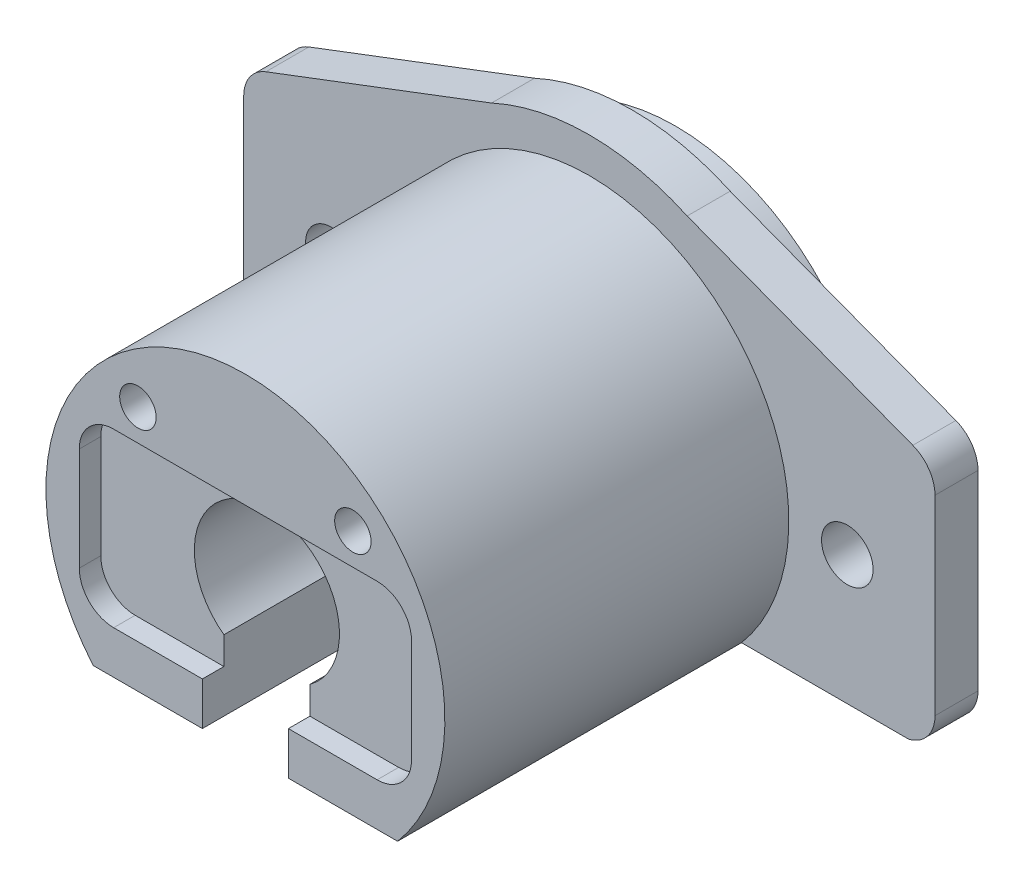
from build123d import *

# Parameters (mm, degrees)
BOSS_EXTRUDE1_DEPTH      = 3.175
FILLET2_R                = 2.54
SKETCH2_R                = 1.905
CUT_EXTRUDE1_DEPTH       = 3.175
SKETCH3_R                = 14.732
BOSS_EXTRUDE2_DEPTH      = 25.4
BOSS_EXTRUDE2_DEPTH_BACK = 6.35
SKETCH4_R                = 5.3594
CUT_EXTRUDE2_DEPTH       = 32.75
SKETCH5_W                = 6.35
SKETCH5_H                = 39.068308628
CUT_EXTRUDE3_DEPTH       = 18.3355
SKETCH6_W                = 53.776347276
SKETCH6_H                = 42.154212624
CUT_EXTRUDE4_DEPTH       = 3.175
CUT_EXTRUDE4_DEPTH_BACK  = 5.342269076
SKETCH8_W                = 24.5364
SKETCH8_H                = 12.7
CUT_EXTRUDE5_DEPTH       = 1.5875
FILLET4_R                = 2.54
SKETCH9_R                = 1.3462
CUT_EXTRUDE6_DEPTH       = 1.5875
CUT_EXTRUDE6_DEPTH_BACK  = 9.525
SKETCH10_W               = 22.477206144
SKETCH10_H               = 0.381
CUT_EXTRUDE7_DEPTH       = 0.79375


with BuildPart() as part:
    # Sketch1 → Boss-Extrude1 (new body)
    with BuildSketch(Plane.XY):
        with BuildLine():
            Line((7.225764579, -15.757788122), (25.527, -8.80240377))
            Line((25.527, -8.80240377), (25.527, 8.80240377))
            Line((25.527, 8.80240377), (7.225764579, 15.757788122))
            ThreePointArc((7.225764579, 15.757788122), (0, 17.3355), (-7.225764579, 15.757788122))
            Line((-7.225764579, 15.757788122), (-25.527, 8.80240377))
            Line((-25.527, 8.80240377), (-25.527, -8.80240377))
            Line((-25.527, -8.80240377), (-7.225764579, -15.757788122))
            ThreePointArc((-7.225764579, -15.757788122), (0, -17.3355), (7.225764579, -15.757788122))
        make_face()
    extrude(amount=BOSS_EXTRUDE1_DEPTH)

    # Fillet2
    fillet2_edges = [part.edges().sort_by_distance(p)[0] for p in [
        (-25.527, -8.80240377, 1.5875),
        (-25.527, 8.80240377, 1.5875),
        (25.527, 8.80240377, 1.5875),
        (25.527, -8.80240377, 1.5875),
    ]]
    fillet(fillet2_edges, radius=FILLET2_R)

    # Sketch2 → Cut-Extrude1 (cut)
    with BuildSketch(Plane.XY.offset(3.175)):
        with Locations((19.05, 0)):
            Circle(SKETCH2_R)
        with Locations((-19.05, 0)):
            Circle(SKETCH2_R)
    extrude(amount=-CUT_EXTRUDE1_DEPTH, mode=Mode.SUBTRACT)

    # Sketch3 → Boss-Extrude2 (add, two sides)
    with BuildSketch(Plane.XY.offset(3.175)) as boss_extrude2_sk:
        Circle(SKETCH3_R)
    extrude(amount=BOSS_EXTRUDE2_DEPTH)
    extrude(boss_extrude2_sk.sketch, amount=-BOSS_EXTRUDE2_DEPTH_BACK)

    # Sketch4 → Cut-Extrude2 (cut, through all)
    with BuildSketch(Plane.XY.offset(28.575)):
        Circle(SKETCH4_R)
    extrude(amount=-CUT_EXTRUDE2_DEPTH, mode=Mode.SUBTRACT)

    # Sketch5 → Cut-Extrude3 (cut, through all)
    with BuildSketch(Plane(origin=(0, 0, 0), x_dir=(1, 0, 0), z_dir=(0, 1, 0))):
        with Locations((0, -13.377136562)):
            Rectangle(SKETCH5_W, SKETCH5_H)
    extrude(amount=-CUT_EXTRUDE3_DEPTH, mode=Mode.SUBTRACT)

    # Sketch6 → Cut-Extrude4 (cut, two sides)
    with BuildSketch(Plane(origin=(0, -12.7, 0), x_dir=(1, 0, 0), z_dir=(0, 1, 0))) as cut_extrude4_sk:
        with Locations((0, -11.260406522)):
            Rectangle(SKETCH6_W, SKETCH6_H)
    extrude(amount=CUT_EXTRUDE4_DEPTH, mode=Mode.SUBTRACT)
    extrude(cut_extrude4_sk.sketch, amount=-CUT_EXTRUDE4_DEPTH_BACK, mode=Mode.SUBTRACT)

    # Sketch8 → Cut-Extrude5 (cut)
    with BuildSketch(Plane.XY.offset(28.575)):
        Rectangle(SKETCH8_W, SKETCH8_H)
    extrude(amount=-CUT_EXTRUDE5_DEPTH, mode=Mode.SUBTRACT)

    # Fillet4
    fillet4_edges = [part.edges().sort_by_distance(p)[0] for p in [
        (12.2682, -6.35, 27.78125),
        (12.2682, 6.35, 27.78125),
        (-12.2682, -6.35, 27.78125),
        (-12.2682, 6.35, 27.78125),
    ]]
    fillet(fillet4_edges, radius=FILLET4_R)

    # Sketch9 → Cut-Extrude6 (cut, two sides)
    with BuildSketch(Plane.XY.offset(26.9875)) as cut_extrude6_sk:
        with Locations((7.9375, 8.662302327)):
            Circle(SKETCH9_R)
        with Locations((-7.9375, 8.662302327)):
            Circle(SKETCH9_R)
    extrude(amount=CUT_EXTRUDE6_DEPTH, mode=Mode.SUBTRACT)
    extrude(cut_extrude6_sk.sketch, amount=-CUT_EXTRUDE6_DEPTH_BACK, mode=Mode.SUBTRACT)

    # Sketch10 → Cut-Extrude7 (cut)
    with BuildSketch(Plane.XZ.offset(9.525)):
        with Locations((0, 11.7475)):
            Rectangle(SKETCH10_W, SKETCH10_H)
        with Locations((0, 3.2475)):
            Rectangle(SKETCH10_W, SKETCH10_H)
        with BuildLine():
            Line((-5.28614634, 12.786699481), (-5.143678391, 12.786699481))
            add(Edge.make_bspline(
                [(-5.143678391, 12.786699481), (-5.14753808, 12.770719033), (-5.155083456, 12.739478564), (-5.170821284, 12.694843842), (-5.187965946, 12.652605673), (-5.208553147, 12.613554954), (-5.231008904, 12.576906881), (-5.25673671, 12.54349267), (-5.284549584, 12.512462504), (-5.315313043, 12.484924714), (-5.347574972, 12.459988387), (-5.38178996, 12.4387272), (-5.417269629, 12.420437317), (-5.454259801, 12.405369569), (-5.4928706, 12.394018706), (-5.532752965, 12.385783298), (-5.574011409, 12.380435185), (-5.602018352, 12.379913232), (-5.616239489, 12.379648199)],
                knots=[0, 0, 0, 0, 4.9287e-05, 9.6353e-05, 0.000141828, 0.000185921, 0.00022863, 0.000270609, 0.000312258, 0.000353458, 0.000394292, 0.00043444, 0.000474121, 0.000513923, 0.000554069, 0.000594671, 0.000636008, 0.000678651, 0.000678651, 0.000678651, 0.000678651], degree=3))
            add(Edge.make_bspline(
                [(-5.616239489, 12.379648199), (-5.636959875, 12.380273778), (-5.677948677, 12.381511291), (-5.738166201, 12.392811768), (-5.796235509, 12.410693882), (-5.851520989, 12.435401608), (-5.902873635, 12.465875853), (-5.948564691, 12.502145573), (-5.987974837, 12.543510971), (-6.021037644, 12.589200384), (-6.046925233, 12.638029847), (-6.06601441, 12.688285633), (-6.077635672, 12.739848527), (-6.079141782, 12.774663436), (-6.07989634, 12.792105631)],
                knots=[0, 0, 0, 0, 6.211e-05, 0.000122866, 0.000183117, 0.000244047, 0.000304093, 0.000361803, 0.000418486, 0.000474973, 0.000530457, 0.000583793, 0.000635878, 0.00068817, 0.00068817, 0.00068817, 0.00068817], degree=3))
            add(Edge.make_bspline(
                [(-6.07989634, 12.792105631), (-6.079368568, 12.808890855), (-6.078335801, 12.841736936), (-6.069566584, 12.889689186), (-6.054809065, 12.934883769), (-6.034366708, 12.977510939), (-6.007904648, 13.01730042), (-5.975849532, 13.054341735), (-5.93797511, 13.088799174), (-5.909273592, 13.108538364), (-5.894497201, 13.118700683)],
                knots=[0, 0, 0, 0, 5.0327e-05, 9.8482e-05, 0.000145647, 0.000192584, 0.00023986, 0.000288564, 0.000339219, 0.000392971, 0.000392971, 0.000392971, 0.000392971], degree=3))
            add(Edge.make_bspline(
                [(-5.894497201, 13.118700683), (-5.911405986, 13.126825507), (-5.944961473, 13.142949221), (-5.990237619, 13.175072719), (-6.031965503, 13.211251751), (-6.054962837, 13.239800604), (-6.066539969, 13.254172438)],
                knots=[0, 0, 0, 0, 5.6181e-05, 0.00011149, 0.000165999, 0.000221257, 0.000221257, 0.000221257, 0.000221257], degree=3))
            add(Edge.make_bspline(
                [(-6.066539969, 13.254172438), (-6.07418183, 13.26462966), (-6.089340412, 13.285372862), (-6.107998245, 13.318743166), (-6.125118065, 13.352372871), (-6.137717756, 13.387584253), (-6.148590791, 13.42324626), (-6.155744885, 13.460122559), (-6.160337528, 13.497862792), (-6.160982429, 13.523406441), (-6.161306596, 13.536246256)],
                knots=[0, 0, 0, 0, 3.8818e-05, 7.7e-05, 0.000114547, 0.000151879, 0.000189009, 0.000226305, 0.000264409, 0.000302921, 0.000302921, 0.000302921, 0.000302921], degree=3))
            add(Edge.make_bspline(
                [(-6.161306596, 13.536246256), (-6.160490747, 13.558474667), (-6.158862887, 13.602826883), (-6.144375392, 13.668371456), (-6.121776732, 13.732323241), (-6.090281753, 13.793775277), (-6.051138262, 13.851096391), (-6.004826188, 13.902530832), (-5.951296217, 13.94633914), (-5.892106911, 13.983266816), (-5.827733123, 14.012531583), (-5.759153873, 14.033619219), (-5.686775199, 14.046268843), (-5.637278697, 14.047786562), (-5.612105374, 14.048558455)],
                knots=[0, 0, 0, 0, 6.6613e-05, 0.000132912, 0.000200403, 0.000269665, 0.000339437, 0.000408104, 0.00047655, 0.00054626, 0.000616846, 0.000688063, 0.000760995, 0.000836477, 0.000836477, 0.000836477, 0.000836477], degree=3))
            add(Edge.make_bspline(
                [(-5.612105374, 14.048558455), (-5.595134117, 14.048161224), (-5.561740342, 14.047379605), (-5.512628969, 14.042131441), (-5.465849206, 14.032285503), (-5.420946805, 14.019902874), (-5.37859945, 14.002782501), (-5.338198015, 13.982371845), (-5.299919594, 13.958147501), (-5.263991509, 13.930068731), (-5.230452146, 13.898638747), (-5.200155975, 13.863335408), (-5.172767802, 13.824817599), (-5.148461649, 13.782738843), (-5.127135219, 13.737216999), (-5.10924746, 13.688069652), (-5.093629236, 13.635677814), (-5.08635362, 13.599177038), (-5.082620698, 13.580449481)],
                knots=[0, 0, 0, 0, 5.0917e-05, 0.000100188, 0.000147899, 0.000194202, 0.000239731, 0.000284673, 0.000329844, 0.00037539, 0.000421283, 0.000467504, 0.000514711, 0.000562874, 0.000613093, 0.000665313, 0.000719655, 0.000776914, 0.000776914, 0.000776914, 0.000776914], degree=3))
            Line((-5.082620698, 13.580449481), (-5.225088647, 13.580449481))
            add(Edge.make_bspline(
                [(-5.225088647, 13.580449481), (-5.228800354, 13.592672783), (-5.236019947, 13.616448168), (-5.248309147, 13.650665736), (-5.262310113, 13.682033853), (-5.277329931, 13.710782626), (-5.29310444, 13.73719518), (-5.310755138, 13.760573099), (-5.328974715, 13.781943208), (-5.342708564, 13.793983086), (-5.349430094, 13.799875563)],
                knots=[0, 0, 0, 0, 3.8321e-05, 7.4538e-05, 0.00010899, 0.000141279, 0.000171821, 0.000201141, 0.000229083, 0.000255865, 0.000255865, 0.000255865, 0.000255865], degree=3))
            add(Edge.make_bspline(
                [(-5.349430094, 13.799875563), (-5.358319534, 13.806725446), (-5.376070974, 13.820404067), (-5.404979522, 13.837909714), (-5.435488831, 13.852894129), (-5.467853327, 13.86507409), (-5.502077352, 13.874216807), (-5.538022079, 13.880797305), (-5.575746483, 13.885141456), (-5.601492652, 13.885536214), (-5.614649444, 13.885737942)],
                knots=[0, 0, 0, 0, 3.3646e-05, 6.7188e-05, 0.000101179, 0.000135496, 0.000170751, 0.000207301, 0.000245053, 0.000284507, 0.000284507, 0.000284507, 0.000284507], degree=3))
            add(Edge.make_bspline(
                [(-5.614649444, 13.885737942), (-5.629505699, 13.88545904), (-5.658555821, 13.88491367), (-5.700941465, 13.879883698), (-5.741277382, 13.872590083), (-5.779151943, 13.86118145), (-5.815080528, 13.84749491), (-5.848261107, 13.829576718), (-5.879669148, 13.809341017), (-5.908384541, 13.785803005), (-5.934272872, 13.760360961), (-5.956643251, 13.73336922), (-5.976018557, 13.705664701), (-5.99159307, 13.676601114), (-6.00391324, 13.64646355), (-6.012295235, 13.615139202), (-6.018124703, 13.582891843), (-6.018599364, 13.560971159), (-6.018838647, 13.549920635)],
                knots=[0, 0, 0, 0, 4.455e-05, 8.7113e-05, 0.000127902, 0.000167348, 0.000205615, 0.000243028, 0.00028025, 0.00031755, 0.000354203, 0.000388976, 0.000422584, 0.000455451, 0.000487694, 0.00052002, 0.000552591, 0.000585702, 0.000585702, 0.000585702, 0.000585702], degree=3))
            add(Edge.make_bspline(
                [(-6.018838647, 13.549920635), (-6.018143098, 13.535129993), (-6.01675546, 13.505622304), (-6.006205047, 13.462193628), (-5.988695923, 13.420334092), (-5.964660502, 13.380591885), (-5.934700766, 13.344189456), (-5.900232913, 13.311605358), (-5.860521504, 13.284474083), (-5.823764224, 13.26578099), (-5.791121185, 13.25332652), (-5.763242373, 13.244593058), (-5.732003298, 13.237611855), (-5.697779319, 13.230858869), (-5.660425993, 13.22519761), (-5.619909698, 13.22045608), (-5.576214124, 13.216668071), (-5.545964978, 13.214975524), (-5.530377109, 13.214103327)],
                knots=[0, 0, 0, 0, 4.4341e-05, 8.8462e-05, 0.000133228, 0.000180022, 0.000227256, 0.000274279, 0.000321825, 0.000371033, 0.00039761, 0.000426578, 0.00045859, 0.000493578, 0.000531223, 0.000571891, 0.000615941, 0.000662776, 0.000662776, 0.000662776, 0.000662776], degree=3))
            Line((-5.530377109, 13.214103327), (-5.530377109, 13.051282814))
            add(Edge.make_bspline(
                [(-5.530377109, 13.051282814), (-5.550009642, 13.050900044), (-5.588451503, 13.050150555), (-5.644763086, 13.042952335), (-5.698445621, 13.031268607), (-5.748691645, 13.014956605), (-5.794252212, 12.995098032), (-5.834156802, 12.972864017), (-5.866969841, 12.94721355), (-5.893279013, 12.919359165), (-5.912792811, 12.889294988), (-5.927196744, 12.858102647), (-5.935716367, 12.825201858), (-5.936855707, 12.802753287), (-5.937428391, 12.791469613)],
                knots=[0, 0, 0, 0, 5.8874e-05, 0.000115279, 0.000169985, 0.000223486, 0.00027347, 0.00031891, 0.000360133, 0.000397935, 0.000433304, 0.000467176, 0.00050065, 0.00053448, 0.00053448, 0.00053448, 0.00053448], degree=3))
            add(Edge.make_bspline(
                [(-5.937428391, 12.791469613), (-5.937244561, 12.783177951), (-5.936878841, 12.766682082), (-5.932082435, 12.742506726), (-5.92520795, 12.719070088), (-5.915220717, 12.696646008), (-5.902304188, 12.675163203), (-5.886677111, 12.65454321), (-5.8682999, 12.634589127), (-5.847291894, 12.615741039), (-5.823846422, 12.598777427), (-5.798904492, 12.583654603), (-5.772368867, 12.570938461), (-5.744412471, 12.560397643), (-5.714884188, 12.552482367), (-5.683939358, 12.546795415), (-5.651514368, 12.543240772), (-5.629392934, 12.542728914), (-5.618147541, 12.542468712)],
                knots=[0, 0, 0, 0, 2.4837e-05, 4.9413e-05, 7.3659e-05, 9.8004e-05, 0.000122819, 0.000148705, 0.000175488, 0.000204089, 0.000233221, 0.000262181, 0.000291481, 0.000321369, 0.000351687, 0.00038306, 0.000415685, 0.000449418, 0.000449418, 0.000449418, 0.000449418], degree=3))
            add(Edge.make_bspline(
                [(-5.618147541, 12.542468712), (-5.600071366, 12.54309857), (-5.564764392, 12.544328829), (-5.513875234, 12.555142251), (-5.466615709, 12.572275004), (-5.430613484, 12.592962752), (-5.403983061, 12.613313954), (-5.38458836, 12.630822093), (-5.365889881, 12.650672737), (-5.34862137, 12.673410367), (-5.331748061, 12.698253126), (-5.315431069, 12.725337841), (-5.300194496, 12.755050658), (-5.290919745, 12.775945568), (-5.28614634, 12.786699481)],
                knots=[0, 0, 0, 0, 5.4175e-05, 0.000105816, 0.000155319, 0.000204466, 0.000229653, 0.000255773, 0.000282772, 0.000311332, 0.000341321, 0.000372844, 0.000406126, 0.000441419, 0.000441419, 0.000441419, 0.000441419], degree=3))
        make_face()
        with BuildLine():
            Line((-6.405537365, 12.847757173), (-6.548005314, 12.847757173))
            Line((-6.548005314, 12.847757173), (-6.548005314, 13.049374761))
            add(Edge.make_bspline(
                [(-6.548005314, 13.049374761), (-6.560861932, 13.031762553), (-6.585454706, 12.998073051), (-6.625395295, 12.953183822), (-6.665982481, 12.915714758), (-6.69500592, 12.895787842), (-6.708917774, 12.88623624)],
                knots=[0, 0, 0, 0, 6.5383e-05, 0.000125068, 0.000180002, 0.000230574, 0.000230574, 0.000230574, 0.000230574], degree=3))
            add(Edge.make_bspline(
                [(-6.708917774, 12.88623624), (-6.727906388, 12.877162378), (-6.765551864, 12.859173184), (-6.82515987, 12.840924392), (-6.886153738, 12.829709792), (-6.927341749, 12.828176098), (-6.948060402, 12.827404609)],
                knots=[0, 0, 0, 0, 6.306e-05, 0.000125019, 0.000186401, 0.00024853, 0.00024853, 0.00024853, 0.00024853], degree=3))
            add(Edge.make_bspline(
                [(-6.948060402, 12.827404609), (-6.962072065, 12.827879989), (-6.989800392, 12.828820739), (-7.030894305, 12.834907351), (-7.070811833, 12.84555568), (-7.109296504, 12.860009459), (-7.145328256, 12.878080347), (-7.178448416, 12.898833967), (-7.208076813, 12.922321066), (-7.234655208, 12.949065303), (-7.258342434, 12.980576772), (-7.279979324, 13.017452829), (-7.300237317, 13.060227018), (-7.311394584, 13.091241791), (-7.317268635, 13.107570374)],
                knots=[0, 0, 0, 0, 4.2036e-05, 8.3187e-05, 0.0001243, 0.000165764, 0.000206296, 0.000245028, 0.000282822, 0.000319476, 0.000357829, 0.000400751, 0.000447551, 0.000499585, 0.000499585, 0.000499585, 0.000499585], degree=3))
            add(Edge.make_bspline(
                [(-7.317268635, 13.107570374), (-7.323487781, 13.096356206), (-7.335726186, 13.074288299), (-7.356273903, 13.043054412), (-7.377809877, 13.013847709), (-7.400482804, 12.986607643), (-7.424387961, 12.96155121), (-7.44913998, 12.938166651), (-7.475293915, 12.917103745), (-7.511466936, 12.892450329), (-7.558414221, 12.866281719), (-7.617855181, 12.843874466), (-7.679575841, 12.829900982), (-7.721597166, 12.828240858), (-7.742764428, 12.827404609)],
                knots=[0, 0, 0, 0, 3.8458e-05, 7.568e-05, 0.000112061, 0.000147281, 0.000181922, 0.000215896, 0.00024937, 0.000282536, 0.000347153, 0.000410056, 0.000472557, 0.000535997, 0.000535997, 0.000535997, 0.000535997], degree=3))
            add(Edge.make_bspline(
                [(-7.742764428, 12.827404609), (-7.762217615, 12.828128945), (-7.800289389, 12.829546541), (-7.855621696, 12.840941462), (-7.907445638, 12.859801097), (-7.955211935, 12.886323619), (-7.998365539, 12.919494445), (-8.036018784, 12.95900803), (-8.067343788, 13.004720057), (-8.088285409, 13.047379627), (-8.102226551, 13.085112424), (-8.110933359, 13.117408605), (-8.118476625, 13.152983313), (-8.124872176, 13.191807935), (-8.129495867, 13.23396108), (-8.132933065, 13.279462115), (-8.135256221, 13.328350579), (-8.135420586, 13.362080614), (-8.135505314, 13.37946791)],
                knots=[0, 0, 0, 0, 5.8321e-05, 0.000114139, 0.000168668, 0.000223185, 0.000277378, 0.000331363, 0.00038623, 0.000442976, 0.00047346, 0.00050679, 0.000543216, 0.000582531, 0.000624778, 0.000670388, 0.000719412, 0.000771569, 0.000771569, 0.000771569, 0.000771569], degree=3))
            Line((-8.135505314, 13.37946791), (-8.135505314, 14.007853327))
            Line((-8.135505314, 14.007853327), (-7.993037365, 14.007853327))
            Line((-7.993037365, 14.007853327), (-7.993037365, 13.378831893))
            add(Edge.make_bspline(
                [(-7.993037365, 13.378831893), (-7.993002211, 13.363990753), (-7.99293465, 13.335468341), (-7.991710641, 13.294532695), (-7.98941607, 13.25721717), (-7.986691869, 13.223473057), (-7.98300953, 13.193310954), (-7.978147703, 13.166815301), (-7.973037952, 13.143865283), (-7.964528973, 13.118433236), (-7.951051695, 13.09040313), (-7.930152088, 13.060388864), (-7.904204064, 13.034078806), (-7.874044919, 13.01110059), (-7.839649565, 12.992781068), (-7.801893206, 12.979206724), (-7.760911584, 12.971181366), (-7.732518003, 12.97031617), (-7.717959741, 12.969872558)],
                knots=[0, 0, 0, 0, 4.4522e-05, 8.5565e-05, 0.000122839, 0.000156669, 0.00018712, 0.000213942, 0.000237468, 0.000257581, 0.000294278, 0.00033036, 0.000366791, 0.000404698, 0.000443683, 0.000483214, 0.000524689, 0.00056833, 0.00056833, 0.00056833, 0.00056833], degree=3))
            add(Edge.make_bspline(
                [(-7.717959741, 12.969872558), (-7.699984943, 12.97070787), (-7.664388234, 12.972362095), (-7.612207818, 12.984386988), (-7.562730863, 13.004877465), (-7.516141008, 13.032497188), (-7.473624855, 13.066569764), (-7.436907429, 13.106868298), (-7.406600556, 13.152523769), (-7.386073533, 13.19476936), (-7.373105346, 13.23271974), (-7.364547476, 13.265875084), (-7.357850479, 13.303659347), (-7.351691263, 13.345629467), (-7.347534524, 13.392142826), (-7.343862501, 13.442912214), (-7.342121931, 13.498285179), (-7.341880609, 13.536669547), (-7.341755314, 13.55659882)],
                knots=[0, 0, 0, 0, 5.3902e-05, 0.000106746, 0.000159659, 0.00021398, 0.000268711, 0.000322511, 0.000376842, 0.000432598, 0.000462869, 0.000497038, 0.00053521, 0.000577934, 0.00062426, 0.000675262, 0.000730628, 0.000790417, 0.000790417, 0.000790417, 0.000790417], degree=3))
            Line((-7.341755314, 13.55659882), (-7.341755314, 14.007853327))
            Line((-7.341755314, 14.007853327), (-7.199287365, 14.007853327))
            Line((-7.199287365, 14.007853327), (-7.199287365, 13.417946977))
            add(Edge.make_bspline(
                [(-7.199287365, 13.417946977), (-7.199252952, 13.401303748), (-7.199186744, 13.369283847), (-7.197951588, 13.323369624), (-7.195714268, 13.28159613), (-7.192824595, 13.244068241), (-7.189688287, 13.210684016), (-7.184725085, 13.181552841), (-7.179551195, 13.156553879), (-7.171656346, 13.128869676), (-7.157976008, 13.098845387), (-7.137192223, 13.066565689), (-7.111236686, 13.038169095), (-7.08073626, 13.013717339), (-7.04601717, 12.993903698), (-7.007746794, 12.97991839), (-6.966449477, 12.971463013), (-6.93792516, 12.970412708), (-6.923255715, 12.969872558)],
                knots=[0, 0, 0, 0, 4.9928e-05, 9.6057e-05, 0.000137776, 0.00017541, 0.000208983, 0.000238313, 0.000264011, 0.000285546, 0.000324551, 0.00036248, 0.0004003, 0.000439436, 0.000479314, 0.000519661, 0.000561197, 0.000605176, 0.000605176, 0.000605176, 0.000605176], degree=3))
            add(Edge.make_bspline(
                [(-6.923255715, 12.969872558), (-6.906012652, 12.970566733), (-6.87164784, 12.9719502), (-6.82116438, 12.98440264), (-6.772412204, 13.003908191), (-6.72616746, 13.030967672), (-6.683683349, 13.064488105), (-6.646472638, 13.103903097), (-6.615309893, 13.148686945), (-6.594421939, 13.190308627), (-6.581043954, 13.227321049), (-6.572229422, 13.258907021), (-6.564679135, 13.29396021), (-6.558349335, 13.332368792), (-6.553571841, 13.374291387), (-6.55071719, 13.419615815), (-6.548206462, 13.468483334), (-6.548074008, 13.502215463), (-6.548005314, 13.519709797)],
                knots=[0, 0, 0, 0, 5.1659e-05, 0.000102954, 0.000155038, 0.000208763, 0.000263097, 0.000316863, 0.000370765, 0.00042623, 0.000456008, 0.000488726, 0.000524529, 0.000563531, 0.000605462, 0.000651048, 0.000699755, 0.00075223, 0.00075223, 0.00075223, 0.00075223], degree=3))
            Line((-6.548005314, 13.519709797), (-6.548005314, 14.007853327))
            Line((-6.548005314, 14.007853327), (-6.405537365, 14.007853327))
            Line((-6.405537365, 14.007853327), (-6.405537365, 12.847757173))
        make_face()
        Polygon((-8.501851468, 12.420353327), (-8.644319416, 12.420353327), (-8.644319416, 13.845032814), (-9.25489634, 13.845032814), (-9.25489634, 14.007853327), (-8.501851468, 14.007853327), align=None)
        with BuildLine():
            Line((-4.83070971, 4.266072028), (-4.688241761, 4.266072028))
            add(Edge.make_bspline(
                [(-4.688241761, 4.266072028), (-4.689170133, 4.24717121), (-4.690993431, 4.210050508), (-4.699535642, 4.155929912), (-4.71174716, 4.104193143), (-4.72905373, 4.055283748), (-4.750425832, 4.008617465), (-4.776591469, 3.964813966), (-4.806992834, 3.923438509), (-4.841574152, 3.885274467), (-4.879098069, 3.85038776), (-4.919339759, 3.819942497), (-4.961885614, 3.794513536), (-5.006366607, 3.773139908), (-5.053297177, 3.757115885), (-5.102228717, 3.7452211), (-5.153382395, 3.738065782), (-5.188234795, 3.737296569), (-5.20596011, 3.736905361)],
                knots=[0, 0, 0, 0, 5.6734e-05, 0.000111424, 0.000164104, 0.000216001, 0.000266797, 0.000317845, 0.000368792, 0.000420582, 0.000472116, 0.000522298, 0.000571655, 0.000620588, 0.000670069, 0.000720126, 0.000771487, 0.000824641, 0.000824641, 0.000824641, 0.000824641], degree=3))
            add(Edge.make_bspline(
                [(-5.20596011, 3.736905361), (-5.223368533, 3.737309568), (-5.257575462, 3.738103821), (-5.307479118, 3.745027213), (-5.355099174, 3.755636695), (-5.399895952, 3.771358276), (-5.442329194, 3.791085421), (-5.481873505, 3.81561871), (-5.519485108, 3.843797311), (-5.553318092, 3.877035352), (-5.584397769, 3.912500426), (-5.611186571, 3.950376828), (-5.634257298, 3.989542192), (-5.653139968, 4.03030246), (-5.667453872, 4.072790365), (-5.678059102, 4.116598561), (-5.684121625, 4.162232625), (-5.685046957, 4.193124702), (-5.685517402, 4.208830441)],
                knots=[0, 0, 0, 0, 5.2201e-05, 0.000102573, 0.000150864, 0.000198334, 0.000244711, 0.000290961, 0.00033771, 0.00038539, 0.000432956, 0.000479018, 0.000524342, 0.000569163, 0.000613513, 0.000658635, 0.000704195, 0.000751313, 0.000751313, 0.000751313, 0.000751313], degree=3))
            add(Edge.make_bspline(
                [(-5.685517402, 4.208830441), (-5.684749374, 4.230941057), (-5.683226797, 4.274774278), (-5.670202953, 4.339188301), (-5.649861183, 4.401596214), (-5.625371696, 4.451825202), (-5.600659693, 4.492295134), (-5.578412864, 4.525632527), (-5.55222116, 4.561518492), (-5.522308349, 4.600098275), (-5.488159291, 4.640866641), (-5.450661175, 4.684655376), (-5.408845598, 4.730654795), (-5.379522826, 4.762093485), (-5.3643285, 4.778384227)],
                knots=[0, 0, 0, 0, 6.6275e-05, 0.000131387, 0.000196351, 0.000262772, 0.00029844, 0.000338571, 0.000382971, 0.000431697, 0.000484995, 0.000542495, 0.000604638, 0.000671469, 0.000671469, 0.000671469, 0.000671469], degree=3))
            Line((-5.3643285, 4.778384227), (-4.967135491, 5.202289976))
            Line((-4.967135491, 5.202289976), (-5.705869966, 5.202289976))
            Line((-5.705869966, 5.202289976), (-5.705869966, 5.365110489))
            Line((-5.705869966, 5.365110489), (-4.627184069, 5.365110489))
            Line((-4.627184069, 5.365110489), (-5.242849133, 4.708104279))
            add(Edge.make_bspline(
                [(-5.242849133, 4.708104279), (-5.257839771, 4.692457687), (-5.28663372, 4.662403784), (-5.327342569, 4.618512713), (-5.363964475, 4.577842172), (-5.39652373, 4.540211938), (-5.425047125, 4.505835342), (-5.449443396, 4.474442981), (-5.469820372, 4.446304255), (-5.491415719, 4.413248057), (-5.512008316, 4.372840499), (-5.530107102, 4.323708737), (-5.541063861, 4.273019593), (-5.54238494, 4.238775744), (-5.543049453, 4.221550794)],
                knots=[0, 0, 0, 0, 6.5005e-05, 0.000124862, 0.000179583, 0.000229184, 0.000274136, 0.000313574, 0.000348435, 0.000378338, 0.000431957, 0.000484068, 0.000535086, 0.000586722, 0.000586722, 0.000586722, 0.000586722], degree=3))
            add(Edge.make_bspline(
                [(-5.543049453, 4.221550794), (-5.542764061, 4.210717677), (-5.542201607, 4.189367684), (-5.537143652, 4.158085817), (-5.529712513, 4.127793809), (-5.518258832, 4.098866197), (-5.504497656, 4.070734031), (-5.486916739, 4.044252618), (-5.466826367, 4.018519269), (-5.443522521, 3.994416359), (-5.417939229, 3.972334351), (-5.390908102, 3.952774917), (-5.362310605, 3.936428496), (-5.332265917, 3.923028439), (-5.300858167, 3.912516741), (-5.268026511, 3.90523303), (-5.23386169, 3.900659903), (-5.210532926, 3.900041154), (-5.198645908, 3.899725874)],
                knots=[0, 0, 0, 0, 3.2476e-05, 6.4004e-05, 9.4855e-05, 0.000125861, 0.000157149, 0.000188638, 0.00022102, 0.000254982, 0.000289027, 0.000322298, 0.000354918, 0.000387659, 0.000420845, 0.000454096, 0.000488413, 0.000524066, 0.000524066, 0.000524066, 0.000524066], degree=3))
            add(Edge.make_bspline(
                [(-5.198645908, 3.899725874), (-5.186228109, 3.900037297), (-5.161841602, 3.900648879), (-5.126113751, 3.905284171), (-5.091791992, 3.912304085), (-5.059405213, 3.923479729), (-5.028275616, 3.936559361), (-4.999197334, 3.953495184), (-4.97135352, 3.972846981), (-4.945303983, 3.995409946), (-4.921578484, 4.020880136), (-4.899995185, 4.048603987), (-4.881707442, 4.079072988), (-4.865473597, 4.111556025), (-4.853057911, 4.146945543), (-4.842443389, 4.184376047), (-4.834733154, 4.224381582), (-4.832073133, 4.251944401), (-4.83070971, 4.266072028)],
                knots=[0, 0, 0, 0, 3.7241e-05, 7.3135e-05, 0.000107939, 0.000142131, 0.000175745, 0.000209075, 0.000242865, 0.000277359, 0.000312231, 0.000347151, 0.000382547, 0.000418672, 0.000455894, 0.000494859, 0.000535336, 0.000577899, 0.000577899, 0.000577899, 0.000577899], degree=3))
        make_face()
        with BuildLine():
            add(Edge.make_bspline(
                [(-6.102744966, 5.12087972), (-6.111591288, 5.121387673), (-6.12883151, 5.1223776), (-6.153795873, 5.129653073), (-6.176608795, 5.141928889), (-6.196803743, 5.158795987), (-6.213588333, 5.178933008), (-6.226005401, 5.201687978), (-6.233614361, 5.226724716), (-6.234554895, 5.244213632), (-6.235036633, 5.253171387)],
                knots=[0, 0, 0, 0, 2.6517e-05, 5.1678e-05, 7.7287e-05, 0.000103712, 0.000130138, 0.000155467, 0.000181023, 0.000207856, 0.000207856, 0.000207856, 0.000207856], degree=3))
            add(Edge.make_bspline(
                [(-6.235036633, 5.253171387), (-6.234537332, 5.261915252), (-6.233551017, 5.279187792), (-6.226001835, 5.304013297), (-6.213604076, 5.326794101), (-6.196697462, 5.346883469), (-6.176730821, 5.364156512), (-6.153723553, 5.376262002), (-6.128895875, 5.384070626), (-6.111602889, 5.384991406), (-6.102744966, 5.385463053)],
                knots=[0, 0, 0, 0, 2.6201e-05, 5.1756e-05, 7.7085e-05, 0.000103511, 0.00013014, 0.000155749, 0.000181, 0.000207517, 0.000207517, 0.000207517, 0.000207517], degree=3))
            add(Edge.make_bspline(
                [(-6.102744966, 5.385463053), (-6.093893418, 5.38497364), (-6.07651122, 5.384012555), (-6.051590632, 5.376417246), (-6.028722744, 5.364038388), (-6.008750914, 5.346914642), (-5.991980203, 5.326689484), (-5.979006875, 5.304168397), (-5.972060014, 5.279115995), (-5.97099392, 5.26190111), (-5.970453299, 5.253171387)],
                knots=[0, 0, 0, 0, 2.6517e-05, 5.2073e-05, 7.7402e-05, 0.000104031, 0.000130457, 0.000155939, 0.000181406, 0.000207606, 0.000207606, 0.000207606, 0.000207606], degree=3))
            add(Edge.make_bspline(
                [(-5.970453299, 5.253171387), (-5.970977816, 5.244228275), (-5.972000126, 5.226797672), (-5.979003715, 5.201533021), (-5.991995975, 5.179037734), (-6.008644984, 5.158765058), (-6.028843538, 5.142045155), (-6.051519687, 5.129499977), (-6.076574578, 5.122434843), (-6.093904763, 5.121405031), (-6.102744966, 5.12087972)],
                knots=[0, 0, 0, 0, 2.6834e-05, 5.23e-05, 7.7783e-05, 0.000104208, 0.000130633, 0.000155962, 0.000181429, 0.000207946, 0.000207946, 0.000207946, 0.000207946], degree=3))
        make_face()
        with BuildLine():
            Line((-7.456190479, 3.777610489), (-7.456190479, 3.940431002))
            Line((-7.456190479, 3.940431002), (-6.916211513, 3.940431002))
            Line((-6.916211513, 3.940431002), (-6.830667142, 4.357976575))
            add(Edge.make_bspline(
                [(-6.830667142, 4.357976575), (-6.847474628, 4.353336416), (-6.880036473, 4.344346842), (-6.928096839, 4.334365653), (-6.973722588, 4.328348827), (-7.003329631, 4.327527268), (-7.017656324, 4.32712972)],
                knots=[0, 0, 0, 0, 5.2298e-05, 0.000101319, 0.000147153, 0.000190126, 0.000190126, 0.000190126, 0.000190126], degree=3))
            add(Edge.make_bspline(
                [(-7.017656324, 4.32712972), (-7.035386785, 4.327500841), (-7.0702493, 4.328230559), (-7.121179122, 4.335650086), (-7.170038007, 4.346403925), (-7.216123182, 4.362945381), (-7.260177637, 4.383275635), (-7.301604102, 4.408549684), (-7.340597172, 4.438407383), (-7.377071614, 4.472236241), (-7.409954604, 4.509900968), (-7.438643248, 4.550431578), (-7.463165158, 4.59337581), (-7.48272638, 4.639128679), (-7.498586254, 4.687259012), (-7.509072821, 4.738170675), (-7.516069414, 4.79144008), (-7.516850081, 4.827864176), (-7.517248171, 4.846438113)],
                knots=[0, 0, 0, 0, 5.3154e-05, 0.000104514, 0.000154116, 0.000202997, 0.000251084, 0.00029946, 0.000348244, 0.000398196, 0.000448455, 0.000497955, 0.000546945, 0.00059651, 0.000646995, 0.000698701, 0.000752227, 0.000807923, 0.000807923, 0.000807923, 0.000807923], degree=3))
            add(Edge.make_bspline(
                [(-7.517248171, 4.846438113), (-7.516946281, 4.859374914), (-7.51634658, 4.885073685), (-7.513302609, 4.923240026), (-7.507422733, 4.960593972), (-7.499613094, 4.997061531), (-7.489228477, 5.032697127), (-7.476948151, 5.067584839), (-7.462249429, 5.10166695), (-7.445476176, 5.134773869), (-7.426392613, 5.166253969), (-7.406026163, 5.19647406), (-7.383833801, 5.224557427), (-7.360204019, 5.250973488), (-7.334683104, 5.27496247), (-7.30789734, 5.297525085), (-7.279247745, 5.317704301), (-7.249239388, 5.33626339), (-7.217893319, 5.352880804), (-7.184891121, 5.366742611), (-7.150957432, 5.378892629), (-7.115789763, 5.388773081), (-7.079456257, 5.396438886), (-7.041831792, 5.401659195), (-7.003105163, 5.405457424), (-6.976854765, 5.405695405), (-6.963594826, 5.405815617)],
                knots=[0, 0, 0, 0, 3.8818e-05, 7.7111e-05, 0.000114756, 0.000152181, 0.000188918, 0.000226032, 0.00026307, 0.00030019, 0.000337276, 0.00037344, 0.000409448, 0.000444573, 0.000479664, 0.000514436, 0.000549556, 0.000584681, 0.000620242, 0.000655861, 0.00069197, 0.000728313, 0.000765361, 0.000803273, 0.000842228, 0.00088199, 0.00088199, 0.00088199, 0.00088199], degree=3))
            add(Edge.make_bspline(
                [(-6.963594826, 5.405815617), (-6.947777317, 5.405501403), (-6.916658237, 5.404883222), (-6.871058949, 5.39844653), (-6.827213989, 5.389164733), (-6.785305203, 5.375420629), (-6.745529674, 5.35739745), (-6.70731042, 5.336120937), (-6.671347043, 5.310441029), (-6.6373844, 5.281278339), (-6.606229408, 5.248933259), (-6.577547727, 5.214545573), (-6.552712986, 5.177352573), (-6.531134044, 5.137974757), (-6.512777341, 5.096309467), (-6.49834365, 5.052259995), (-6.486697592, 5.006040312), (-6.481770129, 4.974220788), (-6.479267402, 4.958059207)],
                knots=[0, 0, 0, 0, 4.7422e-05, 9.3297e-05, 0.000137896, 0.000181742, 0.0002253, 0.000268729, 0.000312758, 0.000357633, 0.000402836, 0.000447341, 0.000491794, 0.000536767, 0.000581907, 0.000628166, 0.000675678, 0.000724717, 0.000724717, 0.000724717, 0.000724717], degree=3))
            Line((-6.479267402, 4.958059207), (-6.621735351, 4.958059207))
            add(Edge.make_bspline(
                [(-6.621735351, 4.958059207), (-6.625236402, 4.973200851), (-6.631965618, 5.00230393), (-6.646813224, 5.0431445), (-6.664679798, 5.079689734), (-6.686910099, 5.11170981), (-6.712161339, 5.140282526), (-6.741305358, 5.165691472), (-6.774094492, 5.188338328), (-6.810536064, 5.207369846), (-6.849079975, 5.223377652), (-6.889184879, 5.234807053), (-6.930281305, 5.241724172), (-6.957950305, 5.242569866), (-6.971863055, 5.242995105)],
                knots=[0, 0, 0, 0, 4.6586e-05, 8.9541e-05, 0.000130073, 0.000168267, 0.000206111, 0.000244194, 0.000283977, 0.000325374, 0.000367303, 0.000408976, 0.000450225, 0.000491944, 0.000491944, 0.000491944, 0.000491944], degree=3))
            add(Edge.make_bspline(
                [(-6.971863055, 5.242995105), (-6.985450197, 5.242619708), (-7.01220339, 5.24188055), (-7.051595088, 5.236283248), (-7.089515136, 5.227436324), (-7.126030845, 5.215042291), (-7.160962786, 5.198645712), (-7.194261567, 5.178503459), (-7.22640156, 5.155118064), (-7.256536888, 5.128389411), (-7.284130469, 5.098917691), (-7.30851309, 5.067405599), (-7.328822519, 5.033788088), (-7.345937659, 4.998648539), (-7.358933969, 4.961601463), (-7.368205416, 4.922820578), (-7.37364966, 4.882210068), (-7.374398589, 4.854510774), (-7.374780223, 4.840395946)],
                knots=[0, 0, 0, 0, 4.075e-05, 8.0237e-05, 0.000119113, 0.000157429, 0.000195699, 0.000234639, 0.000274012, 0.000314787, 0.000355286, 0.000394976, 0.000434081, 0.00047291, 0.000512036, 0.000551604, 0.000592352, 0.00063469, 0.00063469, 0.00063469, 0.00063469], degree=3))
            add(Edge.make_bspline(
                [(-7.374780223, 4.840395946), (-7.374539002, 4.827652359), (-7.374068567, 4.80279937), (-7.368505058, 4.766472382), (-7.361011449, 4.731796269), (-7.349192679, 4.699095023), (-7.334837113, 4.668027246), (-7.316132404, 4.639360583), (-7.295453134, 4.611693353), (-7.270688296, 4.58685468), (-7.243873683, 4.56373817), (-7.214158251, 4.544132118), (-7.182391205, 4.527451018), (-7.148498514, 4.513785848), (-7.112442554, 4.50289994), (-7.074202761, 4.49537668), (-7.033770742, 4.49087484), (-7.006113929, 4.490264146), (-6.99189761, 4.489950233)],
                knots=[0, 0, 0, 0, 3.8194e-05, 7.4488e-05, 0.000110051, 0.000144449, 0.000178588, 0.000212466, 0.00024694, 0.000282022, 0.000317447, 0.000352992, 0.000388553, 0.00042493, 0.000462457, 0.000501374, 0.000541689, 0.000584332, 0.000584332, 0.000584332, 0.000584332], degree=3))
            add(Edge.make_bspline(
                [(-6.99189761, 4.489950233), (-6.979485845, 4.49020463), (-6.954077033, 4.490725421), (-6.915011029, 4.494823934), (-6.874137168, 4.501129103), (-6.831296763, 4.510216864), (-6.786607384, 4.521595366), (-6.739994712, 4.535805689), (-6.691457619, 4.552174189), (-6.65878868, 4.564870155), (-6.642087915, 4.571360489)],
                knots=[0, 0, 0, 0, 3.7229e-05, 7.6213e-05, 0.000117726, 0.00016126, 0.000207538, 0.000256029, 0.000307418, 0.000361164, 0.000361164, 0.000361164, 0.000361164], degree=3))
            Line((-6.642087915, 4.571360489), (-6.804908428, 3.777610489))
            Line((-6.804908428, 3.777610489), (-7.456190479, 3.777610489))
        make_face()
        with BuildLine():
            Line((-7.781831505, 4.205014335), (-7.924299453, 4.205014335))
            Line((-7.924299453, 4.205014335), (-7.924299453, 4.406631924))
            add(Edge.make_bspline(
                [(-7.924299453, 4.406631924), (-7.937156072, 4.389019715), (-7.961748846, 4.355330213), (-8.001689434, 4.310440984), (-8.04227662, 4.27297192), (-8.071300059, 4.253045004), (-8.085211913, 4.243493402)],
                knots=[0, 0, 0, 0, 6.5383e-05, 0.000125068, 0.000180002, 0.000230574, 0.000230574, 0.000230574, 0.000230574], degree=3))
            add(Edge.make_bspline(
                [(-8.085211913, 4.243493402), (-8.104200528, 4.23441954), (-8.141846004, 4.216430347), (-8.201454009, 4.198181554), (-8.262447877, 4.186966954), (-8.303635889, 4.18543326), (-8.324354541, 4.184661771)],
                knots=[0, 0, 0, 0, 6.306e-05, 0.000125019, 0.000186401, 0.00024853, 0.00024853, 0.00024853, 0.00024853], degree=3))
            add(Edge.make_bspline(
                [(-8.324354541, 4.184661771), (-8.338366204, 4.185137151), (-8.366094532, 4.186077902), (-8.407188445, 4.192164514), (-8.447105972, 4.202812843), (-8.485590643, 4.217266622), (-8.521622395, 4.23533751), (-8.554742556, 4.256091129), (-8.584370953, 4.279578228), (-8.610949348, 4.306322465), (-8.634636573, 4.337833934), (-8.656273463, 4.374709991), (-8.676531457, 4.41748418), (-8.687688724, 4.448498954), (-8.693562775, 4.464827537)],
                knots=[0, 0, 0, 0, 4.2036e-05, 8.3187e-05, 0.0001243, 0.000165764, 0.000206296, 0.000245028, 0.000282822, 0.000319476, 0.000357829, 0.000400751, 0.000447551, 0.000499585, 0.000499585, 0.000499585, 0.000499585], degree=3))
            add(Edge.make_bspline(
                [(-8.693562775, 4.464827537), (-8.69978192, 4.453613369), (-8.712020325, 4.431545461), (-8.732568043, 4.400311575), (-8.754104016, 4.371104871), (-8.776776943, 4.343864805), (-8.8006821, 4.318808372), (-8.825434119, 4.295423813), (-8.851588054, 4.274360907), (-8.887761075, 4.249707492), (-8.93470836, 4.223538881), (-8.994149321, 4.201131628), (-9.055869981, 4.187158144), (-9.097891305, 4.18549802), (-9.119058568, 4.184661771)],
                knots=[0, 0, 0, 0, 3.8458e-05, 7.568e-05, 0.000112061, 0.000147281, 0.000181922, 0.000215896, 0.00024937, 0.000282536, 0.000347153, 0.000410056, 0.000472557, 0.000535997, 0.000535997, 0.000535997, 0.000535997], degree=3))
            add(Edge.make_bspline(
                [(-9.119058568, 4.184661771), (-9.138511754, 4.185386107), (-9.176583528, 4.186803703), (-9.231915835, 4.198198624), (-9.283739778, 4.21705826), (-9.331506075, 4.243580781), (-9.374659678, 4.276751607), (-9.412312924, 4.316265192), (-9.443637927, 4.36197722), (-9.464579548, 4.404636789), (-9.47852069, 4.442369586), (-9.487227499, 4.474665767), (-9.494770764, 4.510240475), (-9.501166316, 4.549065097), (-9.505790007, 4.591218242), (-9.509227204, 4.636719277), (-9.51155036, 4.685607741), (-9.511714726, 4.719337776), (-9.511799453, 4.736725073)],
                knots=[0, 0, 0, 0, 5.8321e-05, 0.000114139, 0.000168668, 0.000223185, 0.000277378, 0.000331363, 0.00038623, 0.000442976, 0.00047346, 0.00050679, 0.000543216, 0.000582531, 0.000624778, 0.000670388, 0.000719412, 0.000771569, 0.000771569, 0.000771569, 0.000771569], degree=3))
            Line((-9.511799453, 4.736725073), (-9.511799453, 5.365110489))
            Line((-9.511799453, 5.365110489), (-9.369331505, 5.365110489))
            Line((-9.369331505, 5.365110489), (-9.369331505, 4.736089055))
            add(Edge.make_bspline(
                [(-9.369331505, 4.736089055), (-9.369296351, 4.721247916), (-9.36922879, 4.692725503), (-9.368004781, 4.651789857), (-9.365710209, 4.614474332), (-9.362986008, 4.580730219), (-9.359303669, 4.550568116), (-9.354441843, 4.524072463), (-9.349332091, 4.501122445), (-9.340823113, 4.475690399), (-9.327345835, 4.447660293), (-9.306446227, 4.417646026), (-9.280498204, 4.391335968), (-9.250339058, 4.368357752), (-9.215943705, 4.35003823), (-9.178187345, 4.336463886), (-9.137205723, 4.328438529), (-9.108812143, 4.327573333), (-9.09425388, 4.32712972)],
                knots=[0, 0, 0, 0, 4.4522e-05, 8.5565e-05, 0.000122839, 0.000156669, 0.00018712, 0.000213942, 0.000237468, 0.000257581, 0.000294278, 0.00033036, 0.000366791, 0.000404698, 0.000443683, 0.000483214, 0.000524689, 0.00056833, 0.00056833, 0.00056833, 0.00056833], degree=3))
            add(Edge.make_bspline(
                [(-9.09425388, 4.32712972), (-9.076279082, 4.327965032), (-9.040682373, 4.329619258), (-8.988501957, 4.34164415), (-8.939025002, 4.362134628), (-8.892435148, 4.38975435), (-8.849918995, 4.423826926), (-8.813201569, 4.46412546), (-8.782894696, 4.509780931), (-8.762367673, 4.552026522), (-8.749399486, 4.589976902), (-8.740841616, 4.623132246), (-8.734144619, 4.66091651), (-8.727985402, 4.70288663), (-8.723828663, 4.749399988), (-8.720156641, 4.800169377), (-8.718416071, 4.855542341), (-8.718174748, 4.89392671), (-8.718049453, 4.913855982)],
                knots=[0, 0, 0, 0, 5.3902e-05, 0.000106746, 0.000159659, 0.00021398, 0.000268711, 0.000322511, 0.000376842, 0.000432598, 0.000462869, 0.000497038, 0.00053521, 0.000577934, 0.00062426, 0.000675262, 0.000730628, 0.000790417, 0.000790417, 0.000790417, 0.000790417], degree=3))
            Line((-8.718049453, 4.913855982), (-8.718049453, 5.365110489))
            Line((-8.718049453, 5.365110489), (-8.575581505, 5.365110489))
            Line((-8.575581505, 5.365110489), (-8.575581505, 4.775204139))
            add(Edge.make_bspline(
                [(-8.575581505, 4.775204139), (-8.575547091, 4.75856091), (-8.575480883, 4.726541009), (-8.574245727, 4.680626787), (-8.572008407, 4.638853293), (-8.569118734, 4.601325403), (-8.565982426, 4.567941178), (-8.561019224, 4.538810003), (-8.555845335, 4.513811041), (-8.547950486, 4.486126838), (-8.534270147, 4.456102549), (-8.513486363, 4.423822851), (-8.487530825, 4.395426258), (-8.457030399, 4.370974501), (-8.42231131, 4.351160861), (-8.384040933, 4.337175552), (-8.342743617, 4.328720176), (-8.3142193, 4.32766987), (-8.299549854, 4.32712972)],
                knots=[0, 0, 0, 0, 4.9928e-05, 9.6057e-05, 0.000137776, 0.00017541, 0.000208983, 0.000238313, 0.000264011, 0.000285546, 0.000324551, 0.00036248, 0.0004003, 0.000439436, 0.000479314, 0.000519661, 0.000561197, 0.000605176, 0.000605176, 0.000605176, 0.000605176], degree=3))
            add(Edge.make_bspline(
                [(-8.299549854, 4.32712972), (-8.282306791, 4.327823895), (-8.247941979, 4.329207362), (-8.197458519, 4.341659802), (-8.148706343, 4.361165353), (-8.102461599, 4.388224834), (-8.059977488, 4.421745267), (-8.022766777, 4.461160259), (-7.991604033, 4.505944107), (-7.970716078, 4.547565789), (-7.957338093, 4.584578211), (-7.948523561, 4.616164184), (-7.940973275, 4.651217373), (-7.934643475, 4.689625954), (-7.92986598, 4.731548549), (-7.92701133, 4.776872977), (-7.924500602, 4.825740496), (-7.924368147, 4.859472626), (-7.924299453, 4.87696696)],
                knots=[0, 0, 0, 0, 5.1659e-05, 0.000102954, 0.000155038, 0.000208763, 0.000263097, 0.000316863, 0.000370765, 0.00042623, 0.000456008, 0.000488726, 0.000524529, 0.000563531, 0.000605462, 0.000651048, 0.000699755, 0.00075223, 0.00075223, 0.00075223, 0.00075223], degree=3))
            Line((-7.924299453, 4.87696696), (-7.924299453, 5.365110489))
            Line((-7.924299453, 5.365110489), (-7.781831505, 5.365110489))
            Line((-7.781831505, 5.365110489), (-7.781831505, 4.205014335))
        make_face()
        Polygon((-9.878145607, 3.777610489), (-10.020613556, 3.777610489), (-10.020613556, 5.202289976), (-10.631190479, 5.202289976), (-10.631190479, 5.365110489), (-9.878145607, 5.365110489), align=None)
    extrude(amount=-CUT_EXTRUDE7_DEPTH, mode=Mode.SUBTRACT)


solid = part.part
